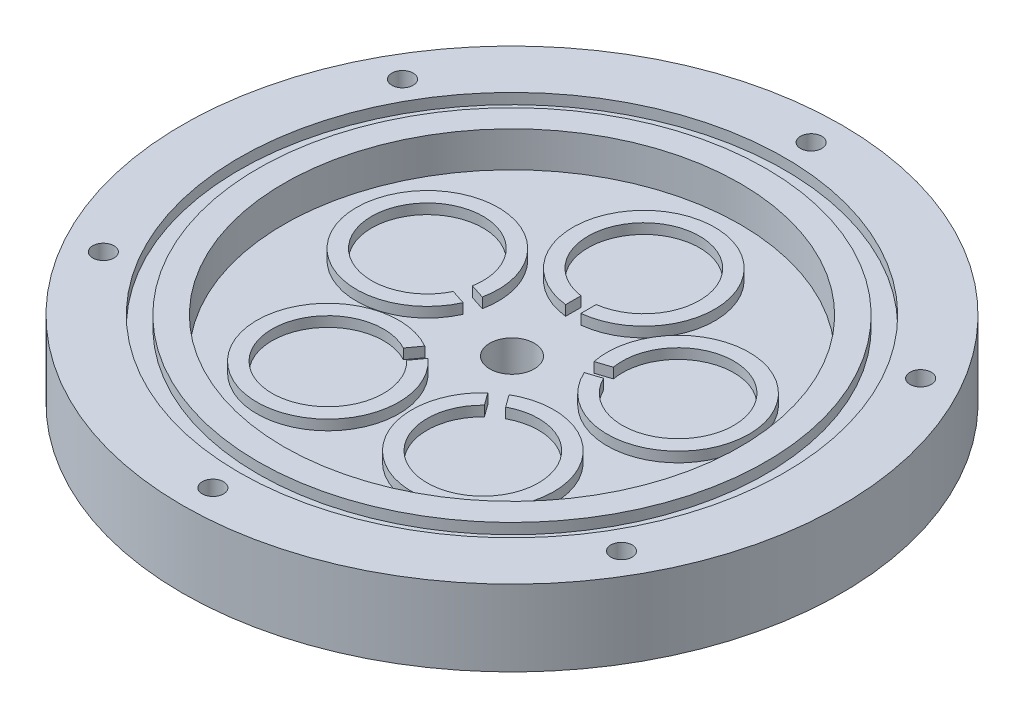
from build123d import *

# Parameters (mm, degrees)
CROQUIS2_R              = 65
SALIENTE_EXTRUIR1_DEPTH = 15
CROQUIS2_3_R            = 45
CORTAR_EXTRUIR1_DEPTH   = 7
TALADRO_ROSCADO_G1_81_D = 8.8
CROQUIS3_R              = 14
CROQUIS3_R_2            = 11
SALIENTE_EXTRUIR3_DEPTH = 2
CORTAR_EXTRUIR3_DEPTH   = 93.271338995
MATRIZC1_COUNT          = 5
CROQUIS7_W              = 3.7
CROQUIS7_H              = 4.2
TALADRO_ROSCADO_M51_D   = 4.2
MATRIZC2_COUNT          = 6


with BuildPart() as part:
    # Croquis2 → Saliente-Extruir1 (new body)
    with BuildSketch(Plane(origin=(0, 0, 0), x_dir=(1, 0, 0), z_dir=(0, 1, 0))):
        Circle(CROQUIS2_R)
    extrude(amount=-SALIENTE_EXTRUIR1_DEPTH)

    # Croquis2_3 → Cortar-Extruir1 (cut)
    with BuildSketch(Plane(origin=(0, 0, 0), x_dir=(1, 0, 0), z_dir=(0, 1, 0))):
        Circle(CROQUIS2_3_R)
    extrude(amount=-CORTAR_EXTRUIR1_DEPTH, mode=Mode.SUBTRACT)

    # Taladro roscado G1_81 (through all)
    with Locations(Plane(origin=(0, -15, 0), x_dir=(-1, 0, 0), z_dir=(0, -1, 0))):
        with Locations((0, 0)):
            Hole(TALADRO_ROSCADO_G1_81_D / 2)

    # Croquis3 → Saliente-Extruir3 (add)
    with BuildSketch(Plane(origin=(0, -7, 0), x_dir=(1, 0, 0), z_dir=(0, 1, 0))):
        with Locations((0, 26)):
            Circle(CROQUIS3_R)
        with Locations((0, 26)):
            Circle(CROQUIS3_R_2, mode=Mode.SUBTRACT)
    saliente_extruir3 = extrude(amount=SALIENTE_EXTRUIR3_DEPTH)

    # Croquis6 → Cortar-Extruir3 (cut, through all)
    with BuildSketch(Plane(origin=(0, -7, 0), x_dir=(1, 0, 0), z_dir=(0, 1, 0))):
        with BuildLine():
            Line((1.5, 26), (1.5, 4.4))
            ThreePointArc((1.5, 4.4), (0, 2.9), (-1.5, 4.4))
            Line((-1.5, 4.4), (-1.5, 26))
            ThreePointArc((-1.5, 26), (0, 27.5), (1.5, 26))
        make_face()
    cortar_extruir3 = extrude(amount=CORTAR_EXTRUIR3_DEPTH, mode=Mode.SUBTRACT)

    # MatrizC1: Saliente-Extruir3, Cortar-Extruir3 ×5 about axis
    matrizc1_axis = Axis((0, -15, 0), (0, 1, 0))
    add([saliente_extruir3.rotate(matrizc1_axis, i * 360 / MATRIZC1_COUNT) for i in range(1, MATRIZC1_COUNT)])
    add([cortar_extruir3.rotate(matrizc1_axis, i * 360 / MATRIZC1_COUNT) for i in range(1, MATRIZC1_COUNT)], mode=Mode.SUBTRACT)

    # Croquis7 → Cortar-Revolución1 (revolve, cut)
    with BuildSketch(Plane(origin=(0, 0, 0), x_dir=(0, 0, -1), z_dir=(1, 0, 0))):
        with Locations((51.945, 0)):
            Rectangle(CROQUIS7_W, CROQUIS7_H)
    revolve(axis=Axis((0, 0, 0), (0, -1, 0)), mode=Mode.SUBTRACT)

    # Taladro roscado M51 (through all)
    with Locations(Plane(origin=(0, 0, 0), x_dir=(1, 0, 0), z_dir=(0, 1, 0))):
        with Locations((0, 59)):
            taladro_roscado_m51 = Hole(TALADRO_ROSCADO_M51_D / 2)

    # MatrizC2: Taladro roscado M51 ×6 about axis
    matrizc2_axis = Axis((0, -15, 0), (0, 1, 0))
    for i in range(1, MATRIZC2_COUNT):
        add(taladro_roscado_m51.rotate(matrizc2_axis, i * 360 / MATRIZC2_COUNT), mode=Mode.SUBTRACT)


solid = part.part
